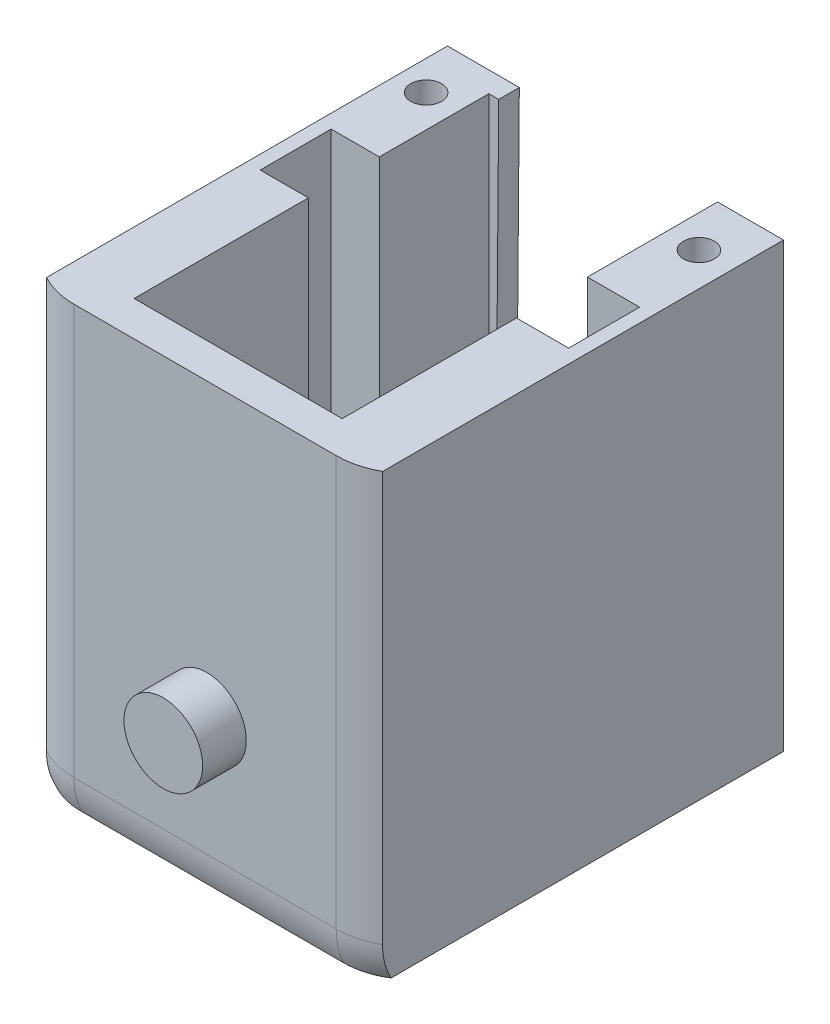
from build123d import *

# Parameters (mm, degrees)
SKETCH1_W           = 27
SKETCH1_H           = 32
BOSS_EXTRUDE1_DEPTH = 31.58
SKETCH3_W           = 20
SKETCH3_H           = 23
CUT_EXTRUDE1_DEPTH  = 30
SKETCH4_W           = 7.5
SKETCH4_H           = 3.655478676
CUT_EXTRUDE2_DEPTH  = 25
SKETCH5_R           = 6.5
SKETCH5_R_2         = 1.269841787
CUT_EXTRUDE4_DEPTH  = 10
SKETCH6_W           = 27
SKETCH6_H           = 3.072558681
CUT_EXTRUDE5_DEPTH  = 32.58
FILLET2_R           = 5
SKETCH7_R           = 2.55
BOSS_EXTRUDE2_DEPTH = 2.83
SKETCH8_W           = 3.381092642
SKETCH8_H           = 7.1
SKETCH8_H_2         = 11.3
SKETCH8_W_2         = 3.125
BOSS_EXTRUDE4_DEPTH = 30
SKETCH11_W          = 2.605806733
SKETCH11_H          = 28.316955939
CUT_EXTRUDE10_DEPTH = 32.58
SKETCH12_W          = 21.788386534
SKETCH12_H          = 2.319503847
CUT_EXTRUDE11_DEPTH = 32.58
SKETCH13_W          = 21.788386534
SKETCH13_H          = 2.858824784
CUT_EXTRUDE12_DEPTH = 30.437937473
CUT_EXTRUDE13_DEPTH = 10
SKETCH15_R          = 1
CUT_EXTRUDE14_DEPTH = 3


with BuildPart() as part:
    # Sketch1 → Boss-Extrude1 (new body)
    with BuildSketch(Plane(origin=(0, 0, 0), x_dir=(1, 0, 0), z_dir=(0, 1, 0))):
        with Locations((13.5, 16)):
            Rectangle(SKETCH1_W, SKETCH1_H)
    extrude(amount=BOSS_EXTRUDE1_DEPTH)

    # Sketch3 → Cut-Extrude1 (cut)
    with BuildSketch(Plane(origin=(0, 31.58, 0), x_dir=(1, 0, 0), z_dir=(0, 1, 0))):
        with Locations((13.5, 16.844521324)):
            Rectangle(SKETCH3_W, SKETCH3_H)
    extrude(amount=-CUT_EXTRUDE1_DEPTH, mode=Mode.SUBTRACT)

    # Sketch4 → Cut-Extrude2 (cut)
    with BuildSketch(Plane(origin=(0, 31.58, 0), x_dir=(1, 0, 0), z_dir=(0, 1, 0))):
        with Locations((13.5, 30.172260662)):
            Rectangle(SKETCH4_W, SKETCH4_H)
    extrude(amount=-CUT_EXTRUDE2_DEPTH, mode=Mode.SUBTRACT)

    # Sketch5 → Cut-Extrude4 (cut)
    with BuildSketch(Plane(origin=(0, 0, -32), x_dir=(-1, 0, 0), z_dir=(0, 0, -1))):
        with Locations((-13.618907358, 13.887482267)):
            Circle(SKETCH5_R)
        with Locations((-13.618907358, 13.887482267)):
            Circle(SKETCH5_R_2, mode=Mode.SUBTRACT)
    extrude(amount=-CUT_EXTRUDE4_DEPTH, mode=Mode.SUBTRACT)

    # Sketch6 → Cut-Extrude5 (cut, through all)
    with BuildSketch(Plane(origin=(0, 31.58, 0), x_dir=(1, 0, 0), z_dir=(0, 1, 0))):
        with Locations((13.5, 1.536279341)):
            Rectangle(SKETCH6_W, SKETCH6_H)
    extrude(amount=-CUT_EXTRUDE5_DEPTH, mode=Mode.SUBTRACT)

    # Fillet2
    fillet2_edges = [part.edges().sort_by_distance(p)[0] for p in [
        (13.5, 0, -32),
        (0, 0, -17.53627934),
        (27, 0, -17.53627934),
        (13.5, 0, -3.072558681),
        (0, 15.79, -3.072558681),
        (27, 15.79, -3.072558681),
        (0, 15.79, -32),
        (27, 15.79, -32),
    ]]
    fillet(fillet2_edges, radius=FILLET2_R)

    # Sketch7 → Boss-Extrude2 (add)
    with BuildSketch(Plane.XY.offset(-3.072558681)):
        with Locations((13.618907358, 12.657)):
            Circle(SKETCH7_R)
    extrude(amount=BOSS_EXTRUDE2_DEPTH)

    # Sketch8 → Boss-Extrude4 (add)
    with BuildSketch(Plane(origin=(0, 31.58, 0), x_dir=(1, 0, 0), z_dir=(0, 1, 0))):
        with Locations((21.809453679, 24.794521324)):
            Rectangle(SKETCH8_W, SKETCH8_H)
        with Locations((21.809453679, 10.994521324)):
            Rectangle(SKETCH8_W, SKETCH8_H_2)
        with Locations((5.0625, 24.794521324)):
            Rectangle(SKETCH8_W_2, SKETCH8_H)
        with Locations((5.0625, 10.994521324)):
            Rectangle(SKETCH8_W_2, SKETCH8_H_2)
    extrude(amount=-BOSS_EXTRUDE4_DEPTH)

    # Sketch11 → Cut-Extrude10 (cut, through all)
    with BuildSketch(Plane(origin=(0, 31.58, 0), x_dir=(1, 0, 0), z_dir=(0, 1, 0))):
        with Locations((1.302903367, 17.841522031)):
            Rectangle(SKETCH11_W, SKETCH11_H)
        Polygon((24.394193267, 18.51018278), (24.394193267, 32), (27, 32), (27, 2.645827608), (24.394193267, 2.645827608), (24.394193267, 18.158757191), align=None)
    extrude(amount=-CUT_EXTRUDE10_DEPTH, mode=Mode.SUBTRACT)

    # Sketch12 → Cut-Extrude11 (cut, through all)
    with BuildSketch(Plane(origin=(0, 31.58, 0), x_dir=(1, 0, 0), z_dir=(0, 1, 0))):
        with Locations((13.5, 30.840248077)):
            Rectangle(SKETCH12_W, SKETCH12_H)
    extrude(amount=-CUT_EXTRUDE11_DEPTH, mode=Mode.SUBTRACT)

    # Sketch13 → Cut-Extrude12 (cut, through all)
    with BuildSketch(Plane(origin=(0, 0, -29.680496153), x_dir=(-1, 0, 0), z_dir=(0, 0, -1))):
        with Locations((-13.5, 1.429412392)):
            Rectangle(SKETCH13_W, SKETCH13_H)
    extrude(amount=-CUT_EXTRUDE12_DEPTH, mode=Mode.SUBTRACT)

    # Sketch14 → Cut-Extrude13 (cut)
    with BuildSketch(Plane(origin=(0, 0, -29.680496153), x_dir=(-1, 0, 0), z_dir=(0, 0, -1))):
        Polygon((-20.118907358, 13.887482267), (-20.118907358, 31.58), (-7.265621144, 31.58), (-7.118907358, 13.887482267), align=None)
    extrude(amount=-CUT_EXTRUDE13_DEPTH, mode=Mode.SUBTRACT)

    # Sketch15 → Cut-Extrude14 (cut)
    with BuildSketch(Plane(origin=(0, 31.58, 0), x_dir=(1, 0, 0), z_dir=(0, 1, 0))):
        with Locations((4.525, 26.375422159)):
            Circle(SKETCH15_R)
        with Locations((22.218907358, 26.375422159)):
            Circle(SKETCH15_R)
    extrude(amount=-CUT_EXTRUDE14_DEPTH, mode=Mode.SUBTRACT)


solid = part.part
